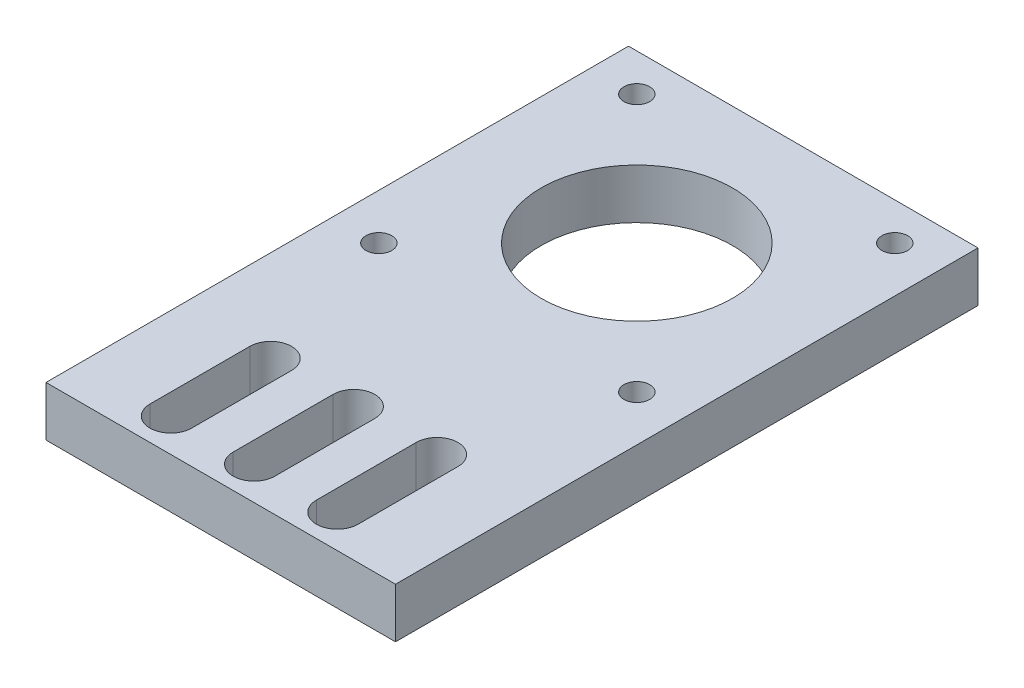
from build123d import *

# Parameters (mm, degrees)
SKETCH1_W           = 42
SKETCH1_H           = 70
SKETCH1_R           = 11.5
SKETCH1_R_2         = 1.55
BOSS_EXTRUDE1_DEPTH = 6


with BuildPart() as part:
    # Sketch1 → Boss-Extrude1 (new body)
    with BuildSketch(Plane(origin=(0, 0, 0), x_dir=(1, 0, 0), z_dir=(0, 1, 0))):
        Rectangle(SKETCH1_W, SKETCH1_H)
        with Locations((0, 15)):
            Circle(SKETCH1_R, mode=Mode.SUBTRACT)
        with Locations((-15.5, 30.5)):
            Circle(SKETCH1_R_2, mode=Mode.SUBTRACT)
        with Locations((15.5, 30.5)):
            Circle(SKETCH1_R_2, mode=Mode.SUBTRACT)
        with Locations((15.5, -0.5)):
            Circle(SKETCH1_R_2, mode=Mode.SUBTRACT)
        with Locations((-15.5, -0.5)):
            Circle(SKETCH1_R_2, mode=Mode.SUBTRACT)
        with BuildLine():
            Line((-7.49, -31), (-7.49, -19))
            ThreePointArc((-7.49, -19), (-10, -16.49), (-12.51, -19))
            Line((-12.51, -19), (-12.51, -31))
            ThreePointArc((-12.51, -31), (-10, -33.51), (-7.49, -31))
        make_face(mode=Mode.SUBTRACT)
        with BuildLine():
            Line((-2.51, -31), (-2.51, -19))
            ThreePointArc((-2.51, -19), (0, -16.49), (2.51, -19))
            Line((2.51, -19), (2.51, -31))
            ThreePointArc((2.51, -31), (0, -33.51), (-2.51, -31))
        make_face(mode=Mode.SUBTRACT)
        with BuildLine():
            Line((7.49, -31), (7.49, -19))
            ThreePointArc((7.49, -19), (10, -16.49), (12.51, -19))
            Line((12.51, -19), (12.51, -31))
            ThreePointArc((12.51, -31), (10, -33.51), (7.49, -31))
        make_face(mode=Mode.SUBTRACT)
    extrude(amount=BOSS_EXTRUDE1_DEPTH)


solid = part.part
